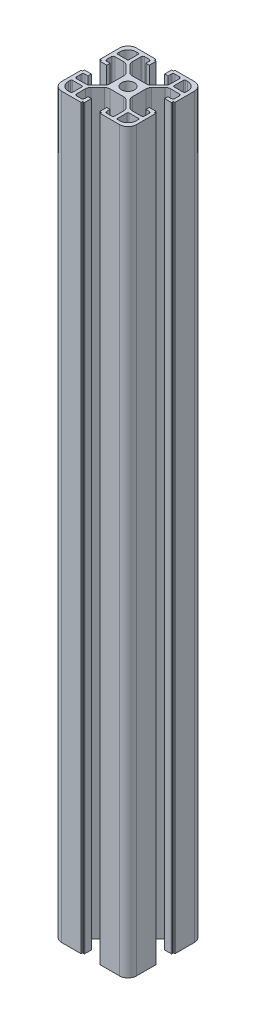
from build123d import *

# Parameters (mm, degrees)
BOSS_EXTRUDE1_DEPTH = 394.54


with BuildPart() as part:
    # Sketch1 → Boss-Extrude1 (new body)
    with BuildSketch(Plane(origin=(0, 0, 0), x_dir=(1, 0, 0), z_dir=(0, 1, 0))):
        with BuildLine():
            Line((84.170223908, 31.720417041), (84.170223908, 42.120417041))
            Line((84.170223908, 42.120417041), (83.570223908, 42.120417041))
            ThreePointArc((83.570223908, 42.120417041), (83.428802552, 42.178995685), (83.370223908, 42.320417041))
            Line((83.370223908, 42.320417041), (83.370223908, 42.920417041))
            ThreePointArc((83.370223908, 42.920417041), (83.311645264, 43.061838398), (83.170223908, 43.120417041))
            Line((83.170223908, 43.120417041), (79.670223908, 43.120417041))
            Line((79.670223908, 43.120417041), (79.670223908, 41.320417041))
            Line((79.670223908, 41.320417041), (81.370223908, 41.320417041))
            ThreePointArc((81.370223908, 41.320417041), (82.077330689, 41.027523823), (82.370223908, 40.320417041))
            Line((82.370223908, 40.320417041), (82.370223908, 37.970417041))
            ThreePointArc((82.370223908, 37.970417041), (82.077330689, 37.26331026), (81.370223908, 36.970417041))
            Line((81.370223908, 36.970417041), (76.723524767, 36.970417041))
            ThreePointArc((76.723524767, 36.970417041), (75.57547447, 37.198778444), (74.602204423, 37.849096698))
            Line((74.602204423, 37.849096698), (71.048903564, 41.402397557))
            ThreePointArc((71.048903564, 41.402397557), (70.39858531, 42.375667603), (70.170223908, 43.5237179))
            Line((70.170223908, 43.5237179), (70.170223908, 50.917116183))
            ThreePointArc((70.170223908, 50.917116183), (70.39858531, 52.06516648), (71.048903564, 53.038436526))
            Line((71.048903564, 53.038436526), (74.602204423, 56.591737385))
            ThreePointArc((74.602204423, 56.591737385), (75.57547447, 57.242055639), (76.723524767, 57.470417041))
            Line((76.723524767, 57.470417041), (81.370223908, 57.470417041))
            ThreePointArc((81.370223908, 57.470417041), (82.077330689, 57.177523823), (82.370223908, 56.470417041))
            Line((82.370223908, 56.470417041), (82.370223908, 54.120417041))
            ThreePointArc((82.370223908, 54.120417041), (82.077330689, 53.41331026), (81.370223908, 53.120417041))
            Line((81.370223908, 53.120417041), (79.670223908, 53.120417041))
            Line((79.670223908, 53.120417041), (79.670223908, 51.320417041))
            Line((79.670223908, 51.320417041), (83.170223908, 51.320417041))
            ThreePointArc((83.170223908, 51.320417041), (83.311645264, 51.378995685), (83.370223908, 51.520417041))
            Line((83.370223908, 51.520417041), (83.370223908, 52.120417041))
            ThreePointArc((83.370223908, 52.120417041), (83.428802552, 52.261838398), (83.570223908, 52.320417041))
            Line((83.570223908, 52.320417041), (84.170223908, 52.320417041))
            Line((84.170223908, 52.320417041), (84.170223908, 62.720417041))
            ThreePointArc((84.170223908, 62.720417041), (82.852204423, 65.902397557), (79.670223908, 67.220417041))
            Line((79.670223908, 67.220417041), (69.470223908, 67.220417041))
            ThreePointArc((69.470223908, 67.220417041), (69.328802552, 67.161838398), (69.270223908, 67.020417041))
            Line((69.270223908, 67.020417041), (69.270223908, 66.620417041))
            ThreePointArc((69.270223908, 66.620417041), (69.211645264, 66.478995685), (69.070223908, 66.420417041))
            Line((69.070223908, 66.420417041), (68.470223908, 66.420417041))
            ThreePointArc((68.470223908, 66.420417041), (68.328802552, 66.361838398), (68.270223908, 66.220417041))
            Line((68.270223908, 66.220417041), (68.270223908, 62.720417041))
            Line((68.270223908, 62.720417041), (70.070223908, 62.720417041))
            Line((70.070223908, 62.720417041), (70.070223908, 64.420417041))
            ThreePointArc((70.070223908, 64.420417041), (70.363117127, 65.127523823), (71.070223908, 65.420417041))
            Line((71.070223908, 65.420417041), (73.420223908, 65.420417041))
            ThreePointArc((73.420223908, 65.420417041), (74.127330689, 65.127523823), (74.420223908, 64.420417041))
            Line((74.420223908, 64.420417041), (74.420223908, 59.7737179))
            ThreePointArc((74.420223908, 59.7737179), (74.191862505, 58.625667603), (73.541544251, 57.652397557))
            Line((73.541544251, 57.652397557), (69.988243393, 54.099096698))
            ThreePointArc((69.988243393, 54.099096698), (69.014973346, 53.448778444), (67.866923049, 53.220417041))
            Line((67.866923049, 53.220417041), (60.473524767, 53.220417041))
            ThreePointArc((60.473524767, 53.220417041), (59.32547447, 53.448778444), (58.352204423, 54.099096698))
            Line((58.352204423, 54.099096698), (54.798903564, 57.652397557))
            ThreePointArc((54.798903564, 57.652397557), (54.14858531, 58.625667603), (53.920223908, 59.7737179))
            Line((53.920223908, 59.7737179), (53.920223908, 64.420417041))
            ThreePointArc((53.920223908, 64.420417041), (54.213117127, 65.127523823), (54.920223908, 65.420417041))
            Line((54.920223908, 65.420417041), (57.270223908, 65.420417041))
            ThreePointArc((57.270223908, 65.420417041), (57.977330689, 65.127523823), (58.270223908, 64.420417041))
            Line((58.270223908, 64.420417041), (58.270223908, 62.720417041))
            Line((58.270223908, 62.720417041), (60.070223908, 62.720417041))
            Line((60.070223908, 62.720417041), (60.070223908, 66.220417041))
            ThreePointArc((60.070223908, 66.220417041), (60.011645264, 66.361838398), (59.870223908, 66.420417041))
            Line((59.870223908, 66.420417041), (59.270223908, 66.420417041))
            ThreePointArc((59.270223908, 66.420417041), (59.128802552, 66.478995685), (59.070223908, 66.620417041))
            Line((59.070223908, 66.620417041), (59.070223908, 67.020417041))
            ThreePointArc((59.070223908, 67.020417041), (59.011645264, 67.161838398), (58.870223908, 67.220417041))
            Line((58.870223908, 67.220417041), (48.670223908, 67.220417041))
            ThreePointArc((48.670223908, 67.220417041), (45.488243393, 65.902397557), (44.170223908, 62.720417041))
            Line((44.170223908, 62.720417041), (44.170223908, 52.320417041))
            Line((44.170223908, 52.320417041), (44.770223908, 52.320417041))
            ThreePointArc((44.770223908, 52.320417041), (44.911645264, 52.261838398), (44.970223908, 52.120417041))
            Line((44.970223908, 52.120417041), (44.970223908, 51.520417041))
            ThreePointArc((44.970223908, 51.520417041), (45.028802552, 51.378995685), (45.170223908, 51.320417041))
            Line((45.170223908, 51.320417041), (48.670223908, 51.320417041))
            Line((48.670223908, 51.320417041), (48.670223908, 53.120417041))
            Line((48.670223908, 53.120417041), (46.970223908, 53.120417041))
            ThreePointArc((46.970223908, 53.120417041), (46.263117127, 53.41331026), (45.970223908, 54.120417041))
            Line((45.970223908, 54.120417041), (45.970223908, 56.470417041))
            ThreePointArc((45.970223908, 56.470417041), (46.263117127, 57.177523823), (46.970223908, 57.470417041))
            Line((46.970223908, 57.470417041), (51.616923049, 57.470417041))
            ThreePointArc((51.616923049, 57.470417041), (52.764973346, 57.242055639), (53.738243393, 56.591737385))
            Line((53.738243393, 56.591737385), (57.291544251, 53.038436526))
            ThreePointArc((57.291544251, 53.038436526), (57.941862505, 52.06516648), (58.170223908, 50.917116183))
            Line((58.170223908, 50.917116183), (58.170223908, 43.5237179))
            ThreePointArc((58.170223908, 43.5237179), (57.941862505, 42.375667603), (57.291544251, 41.402397557))
            Line((57.291544251, 41.402397557), (53.738243393, 37.849096698))
            ThreePointArc((53.738243393, 37.849096698), (52.764973346, 37.198778444), (51.616923049, 36.970417041))
            Line((51.616923049, 36.970417041), (46.970223908, 36.970417041))
            ThreePointArc((46.970223908, 36.970417041), (46.263117127, 37.26331026), (45.970223908, 37.970417041))
            Line((45.970223908, 37.970417041), (45.970223908, 40.320417041))
            ThreePointArc((45.970223908, 40.320417041), (46.263117127, 41.027523823), (46.970223908, 41.320417041))
            Line((46.970223908, 41.320417041), (48.670223908, 41.320417041))
            Line((48.670223908, 41.320417041), (48.670223908, 43.120417041))
            Line((48.670223908, 43.120417041), (45.170223908, 43.120417041))
            ThreePointArc((45.170223908, 43.120417041), (45.028802552, 43.061838398), (44.970223908, 42.920417041))
            Line((44.970223908, 42.920417041), (44.970223908, 42.320417041))
            ThreePointArc((44.970223908, 42.320417041), (44.911645264, 42.178995685), (44.770223908, 42.120417041))
            Line((44.770223908, 42.120417041), (44.170223908, 42.120417041))
            Line((44.170223908, 42.120417041), (44.170223908, 31.720417041))
            ThreePointArc((44.170223908, 31.720417041), (45.488243393, 28.538436526), (48.670223908, 27.220417041))
            Line((48.670223908, 27.220417041), (59.070223908, 27.220417041))
            Line((59.070223908, 27.220417041), (59.070223908, 27.820417041))
            ThreePointArc((59.070223908, 27.820417041), (59.128802552, 27.961838398), (59.270223908, 28.020417041))
            Line((59.270223908, 28.020417041), (59.870223908, 28.020417041))
            ThreePointArc((59.870223908, 28.020417041), (60.011645264, 28.078995685), (60.070223908, 28.220417041))
            Line((60.070223908, 28.220417041), (60.070223908, 31.720417041))
            Line((60.070223908, 31.720417041), (58.270223908, 31.720417041))
            Line((58.270223908, 31.720417041), (58.270223908, 30.020417041))
            ThreePointArc((58.270223908, 30.020417041), (57.977330689, 29.31331026), (57.270223908, 29.020417041))
            Line((57.270223908, 29.020417041), (54.920223908, 29.020417041))
            ThreePointArc((54.920223908, 29.020417041), (54.213117127, 29.31331026), (53.920223908, 30.020417041))
            Line((53.920223908, 30.020417041), (53.920223908, 34.667116183))
            ThreePointArc((53.920223908, 34.667116183), (54.14858531, 35.81516648), (54.798903564, 36.788436526))
            Line((54.798903564, 36.788436526), (58.352204423, 40.341737385))
            ThreePointArc((58.352204423, 40.341737385), (59.32547447, 40.992055639), (60.473524767, 41.220417041))
            Line((60.473524767, 41.220417041), (67.866923049, 41.220417041))
            ThreePointArc((67.866923049, 41.220417041), (69.014973346, 40.992055639), (69.988243393, 40.341737385))
            Line((69.988243393, 40.341737385), (73.541544251, 36.788436526))
            ThreePointArc((73.541544251, 36.788436526), (74.191862505, 35.81516648), (74.420223908, 34.667116183))
            Line((74.420223908, 34.667116183), (74.420223908, 30.020417041))
            ThreePointArc((74.420223908, 30.020417041), (74.127330689, 29.31331026), (73.420223908, 29.020417041))
            Line((73.420223908, 29.020417041), (71.070223908, 29.020417041))
            ThreePointArc((71.070223908, 29.020417041), (70.363117127, 29.31331026), (70.070223908, 30.020417041))
            Line((70.070223908, 30.020417041), (70.070223908, 31.720417041))
            Line((70.070223908, 31.720417041), (68.270223908, 31.720417041))
            Line((68.270223908, 31.720417041), (68.270223908, 28.220417041))
            ThreePointArc((68.270223908, 28.220417041), (68.328802552, 28.078995685), (68.470223908, 28.020417041))
            Line((68.470223908, 28.020417041), (69.070223908, 28.020417041))
            ThreePointArc((69.070223908, 28.020417041), (69.211645264, 27.961838398), (69.270223908, 27.820417041))
            Line((69.270223908, 27.820417041), (69.270223908, 27.220417041))
            Line((69.270223908, 27.220417041), (79.670223908, 27.220417041))
            ThreePointArc((79.670223908, 27.220417041), (82.852204423, 28.538436526), (84.170223908, 31.720417041))
        make_face()
        with BuildLine():
            Line((82.370223908, 34.670417041), (82.370223908, 33.520417041))
            ThreePointArc((82.370223908, 33.520417041), (81.052204423, 30.338436526), (77.870223908, 29.020417041))
            Line((77.870223908, 29.020417041), (76.720223908, 29.020417041))
            ThreePointArc((76.720223908, 29.020417041), (76.366670517, 29.166863651), (76.220223908, 29.520417041))
            Line((76.220223908, 29.520417041), (76.220223908, 34.670417041))
            ThreePointArc((76.220223908, 34.670417041), (76.366670517, 35.023970432), (76.720223908, 35.170417041))
            Line((76.720223908, 35.170417041), (81.870223908, 35.170417041))
            ThreePointArc((81.870223908, 35.170417041), (82.223777298, 35.023970432), (82.370223908, 34.670417041))
        make_face(mode=Mode.SUBTRACT)
        with BuildLine():
            Line((51.620223908, 29.020417041), (50.470223908, 29.020417041))
            ThreePointArc((50.470223908, 29.020417041), (47.288243393, 30.338436526), (45.970223908, 33.520417041))
            Line((45.970223908, 33.520417041), (45.970223908, 34.670417041))
            ThreePointArc((45.970223908, 34.670417041), (46.116670517, 35.023970432), (46.470223908, 35.170417041))
            Line((46.470223908, 35.170417041), (51.620223908, 35.170417041))
            ThreePointArc((51.620223908, 35.170417041), (51.973777298, 35.023970432), (52.120223908, 34.670417041))
            Line((52.120223908, 34.670417041), (52.120223908, 29.520417041))
            ThreePointArc((52.120223908, 29.520417041), (51.973777298, 29.166863651), (51.620223908, 29.020417041))
        make_face(mode=Mode.SUBTRACT)
        with BuildLine():
            Line((45.970223908, 59.770417041), (45.970223908, 60.920417041))
            ThreePointArc((45.970223908, 60.920417041), (47.288243393, 64.102397557), (50.470223908, 65.420417041))
            Line((50.470223908, 65.420417041), (51.620223908, 65.420417041))
            ThreePointArc((51.620223908, 65.420417041), (51.973777298, 65.273970432), (52.120223908, 64.920417041))
            Line((52.120223908, 64.920417041), (52.120223908, 59.770417041))
            ThreePointArc((52.120223908, 59.770417041), (51.973777298, 59.416863651), (51.620223908, 59.270417041))
            Line((51.620223908, 59.270417041), (46.470223908, 59.270417041))
            ThreePointArc((46.470223908, 59.270417041), (46.116670517, 59.416863651), (45.970223908, 59.770417041))
        make_face(mode=Mode.SUBTRACT)
        with BuildLine():
            Line((76.720223908, 65.420417041), (77.870223908, 65.420417041))
            ThreePointArc((77.870223908, 65.420417041), (81.052204423, 64.102397557), (82.370223908, 60.920417041))
            Line((82.370223908, 60.920417041), (82.370223908, 59.770417041))
            ThreePointArc((82.370223908, 59.770417041), (82.223777298, 59.416863651), (81.870223908, 59.270417041))
            Line((81.870223908, 59.270417041), (76.720223908, 59.270417041))
            ThreePointArc((76.720223908, 59.270417041), (76.366670517, 59.416863651), (76.220223908, 59.770417041))
            Line((76.220223908, 59.770417041), (76.220223908, 64.920417041))
            ThreePointArc((76.220223908, 64.920417041), (76.366670517, 65.273970432), (76.720223908, 65.420417041))
        make_face(mode=Mode.SUBTRACT)
        with BuildLine():
            ThreePointArc((60.770223908, 47.220417041), (64.170223908, 43.820417041), (67.570223908, 47.220417041))
            ThreePointArc((67.570223908, 47.220417041), (64.170223908, 50.620417041), (60.770223908, 47.220417041))
        make_face(mode=Mode.SUBTRACT)
    extrude(amount=BOSS_EXTRUDE1_DEPTH)


solid = part.part
